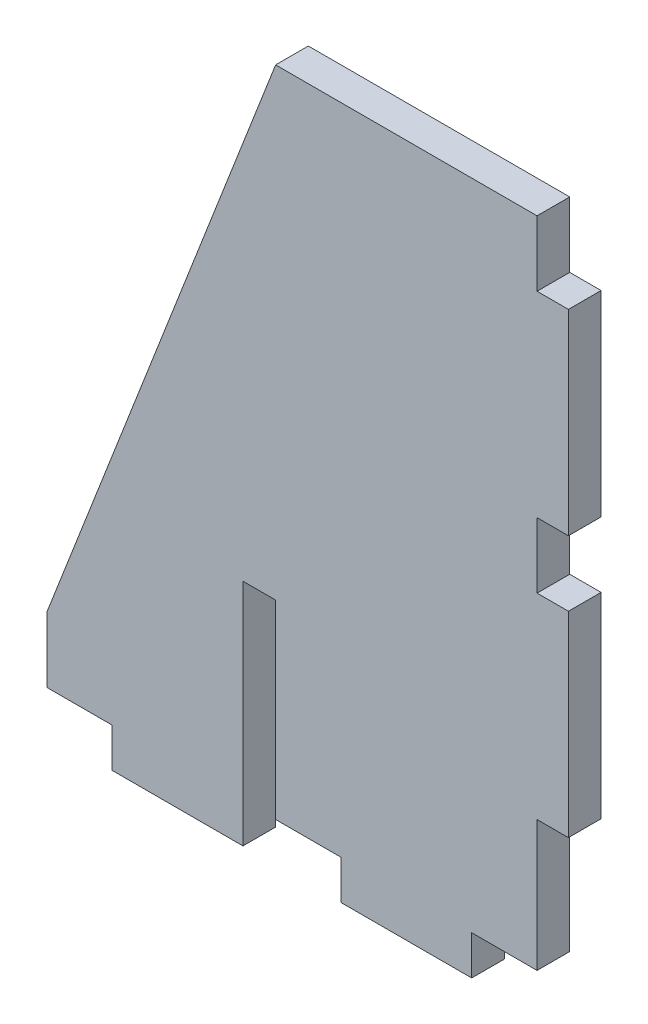
from build123d import *

# Parameters (mm, degrees)
BOSS_EXTRUDE1_DEPTH = 3.175
KERF_DEPTH          = 3.175


with BuildPart() as part:
    # Sketch1 → Boss-Extrude1 (new body)
    with BuildSketch(Plane.XY):
        Polygon((0, 0), (-6.35, 0), (-6.35, -3.81), (-19.05, -3.81), (-19.05, 0), (-25.4, 0), (-25.4, 18.4658), (-28.575, 18.4658), (-28.575, 0), (-28.575, -3.81), (-41.275, -3.81), (-41.275, 0), (-47.625, 0), (-47.625, 6.35), (-25.4, 63.5), (0, 63.5), (0, 57.15), (3.048, 57.15), (3.048, 38.1), (0, 38.1), (0, 31.75), (3.048, 31.75), (3.048, 12.7), (0, 12.7), align=None)
    extrude(amount=BOSS_EXTRUDE1_DEPTH)

    # Sketch2 → kerf (add, through all)
    with BuildSketch(Plane.XY.offset(3.175)):
        Polygon((-25.4, 0), (-19.05, 0), (-19.05, -3.81), (-6.35, -3.81), (-6.35, 0), (0, 0), (0, 12.7), (3.048, 12.7), (3.048, 31.75), (0, 31.75), (0, 38.1), (3.048, 38.1), (3.048, 57.15), (0, 57.15), (0, 63.5), (-25.4, 63.5), (-47.625, 6.35), (-47.625, 0), (-41.275, 0), (-41.275, -3.81), (-28.575, -3.81), (-28.575, 18.4658), (-25.4, 18.4658), align=None)
    extrude(amount=-KERF_DEPTH)


solid = part.part
